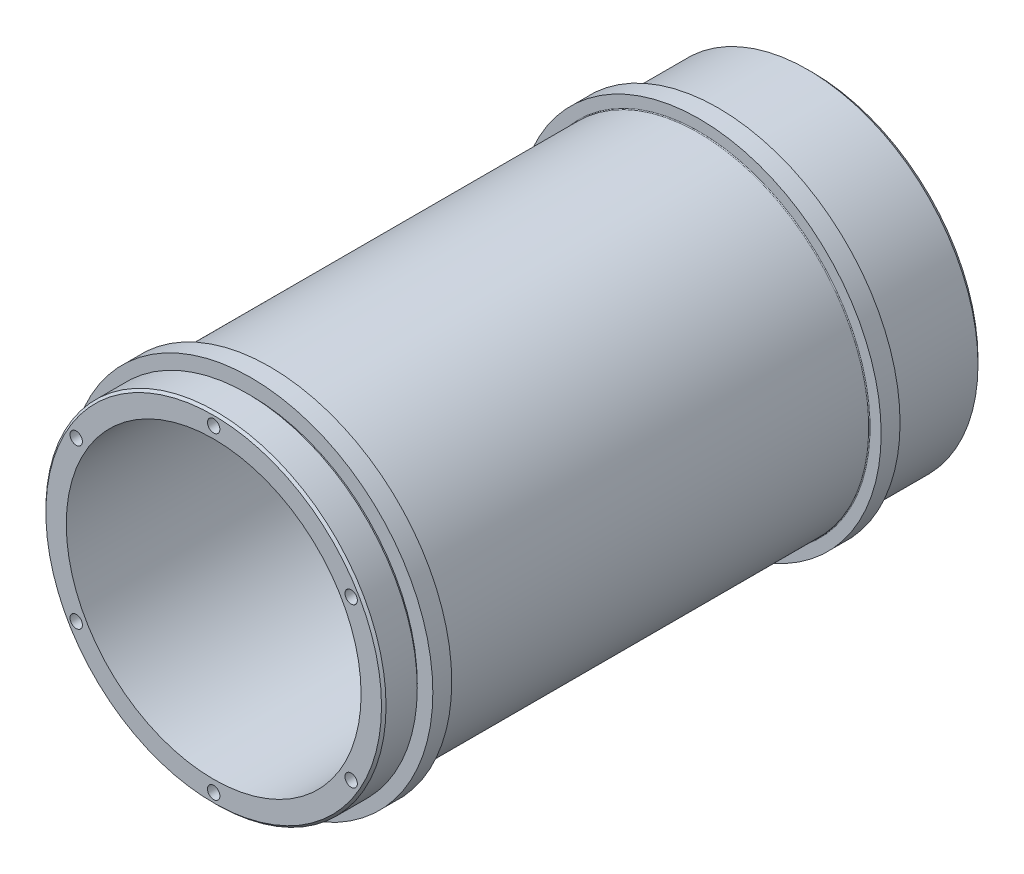
from build123d import *

# Parameters (mm, degrees)
SKETCH1_R                       = 57.15
BOSS_EXTRUDE1_DEPTH             = 201.2442
SKETCH3_W                       = 1.27
SKETCH3_H                       = 1.27
SKETCH9_R                       = 61.1124
BOSS_EXTRUDE4_DEPTH             = 6.35
SKETCH10_R                      = 61.1124
BOSS_EXTRUDE5_DEPTH             = 6.35
F_97_0_164_DIAMETER_HOLE1_D     = 4.1656
F_97_0_164_DIAMETER_HOLE1_DEPTH = 8.255
F_97_0_164_DIAMETER_HOLE1_TIP   = 1.251472497
F_97_0_352_DIAMETER_HOLE1_D     = 8.9408
CUT_EXTRUDE3_DEPTH              = 202.2442
SKETCH20_R                      = 49.53
CUT_EXTRUDE4_DEPTH              = 191.7192
FILLET4_R                       = 0.508
FILLET5_R                       = 0.254
CHAMFER1_SIZE                   = 0.762
CHAMFER2_SIZE                   = 1.6002


with BuildPart() as part:
    # Sketch1 → Boss-Extrude1 (new body)
    with BuildSketch(Plane.XY):
        Circle(SKETCH1_R)
    extrude(amount=BOSS_EXTRUDE1_DEPTH)

    # Sketch3 → Cut-Revolve2 (revolve, cut)
    with BuildSketch(Plane(origin=(0, 0, 0), x_dir=(0, 0, -1), z_dir=(1, 0, 0))):
        with Locations((-31.115, 56.515)):
            Rectangle(SKETCH3_W, SKETCH3_H)
        with Locations((-189.357, 56.515)):
            Rectangle(SKETCH3_W, SKETCH3_H)
    revolve(axis=Axis((0, 0, 212.826037786), (0, 0, -1)), mode=Mode.SUBTRACT)

    # Sketch9 → Boss-Extrude4 (add)
    with BuildSketch(Plane.XY.offset(188.722)):
        Circle(SKETCH9_R)
    extrude(amount=-BOSS_EXTRUDE4_DEPTH)

    # Sketch10 → Boss-Extrude5 (add)
    with BuildSketch(Plane(origin=(0, 0, 31.75), x_dir=(-1, 0, 0), z_dir=(0, 0, -1))):
        Circle(SKETCH10_R)
    extrude(amount=-BOSS_EXTRUDE5_DEPTH)

    # #97 (0.164) Diameter Hole1
    with Locations(Plane.XY.offset(201.2442)):
        with Locations((0, 53.34), (46.193795038, 26.67), (46.193795038, -26.67), (0, -53.34), (-46.193795038, -26.67), (-46.193795038, 26.67)):
            Hole(F_97_0_164_DIAMETER_HOLE1_D / 2, depth=F_97_0_164_DIAMETER_HOLE1_DEPTH)
            with Locations((0, 0, -(F_97_0_164_DIAMETER_HOLE1_DEPTH + F_97_0_164_DIAMETER_HOLE1_TIP / 2))):  # 118° drill point
                Cone(0, F_97_0_164_DIAMETER_HOLE1_D / 2, F_97_0_164_DIAMETER_HOLE1_TIP, mode=Mode.SUBTRACT)

    # #97 (0.352) Diameter Hole1 (through all)
    with Locations(Plane.XY.offset(201.2442)):
        with Locations((0, 38.735), (33.545494016, 19.3675), (33.545494016, -19.3675), (0, -38.735), (-33.545494016, -19.3675), (-33.545494016, 19.3675)):
            Hole(F_97_0_352_DIAMETER_HOLE1_D / 2)

    # Sketch18 → Cut-Extrude3 (cut, through all)
    with BuildSketch(Plane.XY.offset(201.2442)):
        with BuildLine():
            Line((26.579810552, 10.4902), (32.11926165, 10.4902))
            ThreePointArc((32.11926165, 10.4902), (36.312562564, 8.908714176), (38.417156092, 4.952003922))
            ThreePointArc((38.417156092, 4.952003922), (38.655457352, 2.481096914), (38.735, 0))
            ThreePointArc((38.735, 0), (38.655457352, -2.481096914), (38.417156092, -4.952003922))
            ThreePointArc((38.417156092, -4.952003922), (36.312562564, -8.908714176), (32.11926165, -10.4902))
            Line((32.11926165, -10.4902), (26.579810552, -10.4902))
            ThreePointArc((26.579810552, -10.4902), (24.746675913, -14.2875), (22.374684967, -17.773691165))
            Line((22.374684967, -17.773691165), (25.144410516, -22.57099654))
            ThreePointArc((25.144410516, -22.57099654), (25.871454074, -26.993244568), (23.497139241, -30.794231156))
            ThreePointArc((23.497139241, -30.794231156), (21.476421633, -32.236059605), (19.3675, -33.545494016))
            ThreePointArc((19.3675, -33.545494016), (17.179035719, -34.717156519), (14.92001685, -35.746235077))
            ThreePointArc((14.92001685, -35.746235077), (10.44110849, -35.901958745), (6.974851134, -33.06119654))
            Line((6.974851134, -33.06119654), (4.205125585, -28.263891165))
            ThreePointArc((4.205125585, -28.263891165), (0, -28.575), (-4.205125585, -28.263891165))
            Line((-4.205125585, -28.263891165), (-6.974851134, -33.06119654))
            ThreePointArc((-6.974851134, -33.06119654), (-10.44110849, -35.901958745), (-14.92001685, -35.746235077))
            ThreePointArc((-14.92001685, -35.746235077), (-17.179035719, -34.717156519), (-19.3675, -33.545494016))
            ThreePointArc((-19.3675, -33.545494016), (-21.476421633, -32.236059605), (-23.497139241, -30.794231156))
            ThreePointArc((-23.497139241, -30.794231156), (-25.871454074, -26.993244568), (-25.144410516, -22.57099654))
            Line((-25.144410516, -22.57099654), (-22.374684967, -17.773691165))
            ThreePointArc((-22.374684967, -17.773691165), (-24.746675913, -14.2875), (-26.579810552, -10.4902))
            Line((-26.579810552, -10.4902), (-32.11926165, -10.4902))
            ThreePointArc((-32.11926165, -10.4902), (-36.312562564, -8.908714176), (-38.417156092, -4.952003922))
            ThreePointArc((-38.417156092, -4.952003922), (-38.655457352, -2.481096914), (-38.735, 0))
            ThreePointArc((-38.735, 0), (-38.655457352, 2.481096914), (-38.417156092, 4.952003922))
            ThreePointArc((-38.417156092, 4.952003922), (-36.312562564, 8.908714176), (-32.11926165, 10.4902))
            Line((-32.11926165, 10.4902), (-26.579810552, 10.4902))
            ThreePointArc((-26.579810552, 10.4902), (-24.746675913, 14.2875), (-22.374684967, 17.773691165))
            Line((-22.374684967, 17.773691165), (-25.144410516, 22.57099654))
            ThreePointArc((-25.144410516, 22.57099654), (-25.871454074, 26.993244568), (-23.497139241, 30.794231156))
            ThreePointArc((-23.497139241, 30.794231156), (-21.476421633, 32.236059605), (-19.3675, 33.545494016))
            ThreePointArc((-19.3675, 33.545494016), (-17.179035719, 34.717156519), (-14.92001685, 35.746235077))
            ThreePointArc((-14.92001685, 35.746235077), (-10.44110849, 35.901958745), (-6.974851134, 33.06119654))
            Line((-6.974851134, 33.06119654), (-4.205125585, 28.263891165))
            ThreePointArc((-4.205125585, 28.263891165), (0, 28.575), (4.205125585, 28.263891165))
            Line((4.205125585, 28.263891165), (6.974851134, 33.06119654))
            ThreePointArc((6.974851134, 33.06119654), (10.44110849, 35.901958745), (14.92001685, 35.746235077))
            ThreePointArc((14.92001685, 35.746235077), (17.179035719, 34.717156519), (19.3675, 33.545494016))
            ThreePointArc((19.3675, 33.545494016), (21.476421633, 32.236059605), (23.497139241, 30.794231156))
            ThreePointArc((23.497139241, 30.794231156), (25.871454074, 26.993244568), (25.144410516, 22.57099654))
            Line((25.144410516, 22.57099654), (22.374684967, 17.773691165))
            ThreePointArc((22.374684967, 17.773691165), (24.746675913, 14.2875), (26.579810552, 10.4902))
        make_face()
    extrude(amount=-CUT_EXTRUDE3_DEPTH, mode=Mode.SUBTRACT)

    # Sketch20 → Cut-Extrude4 (cut)
    with BuildSketch(Plane.XY.offset(201.2442)):
        Circle(SKETCH20_R)
    extrude(amount=-CUT_EXTRUDE4_DEPTH, mode=Mode.SUBTRACT)

    # Fillet4
    fillet4_edges = [part.edges().sort_by_distance(p)[0] for p in [
        (-49.53, 0, 9.525),
    ]]
    fillet(fillet4_edges, radius=FILLET4_R)

    # Fillet5
    fillet5_edges = [part.edges().sort_by_distance(p)[0] for p in [
        (-57.15, 0, 182.372),
        (-57.15, 0, 38.1),
    ]]
    fillet(fillet5_edges, radius=FILLET5_R)

    # Chamfer1
    chamfer1_edges = [part.edges().sort_by_distance(p)[0] for p in [
        (-57.15, 0, 201.2442),
    ]]
    chamfer(chamfer1_edges, length=CHAMFER1_SIZE)

    # Chamfer2
    chamfer2_edges = [part.edges().sort_by_distance(p)[0] for p in [
        (-57.15, 0, 0),
    ]]
    chamfer(chamfer2_edges, length=CHAMFER2_SIZE)


solid = part.part
